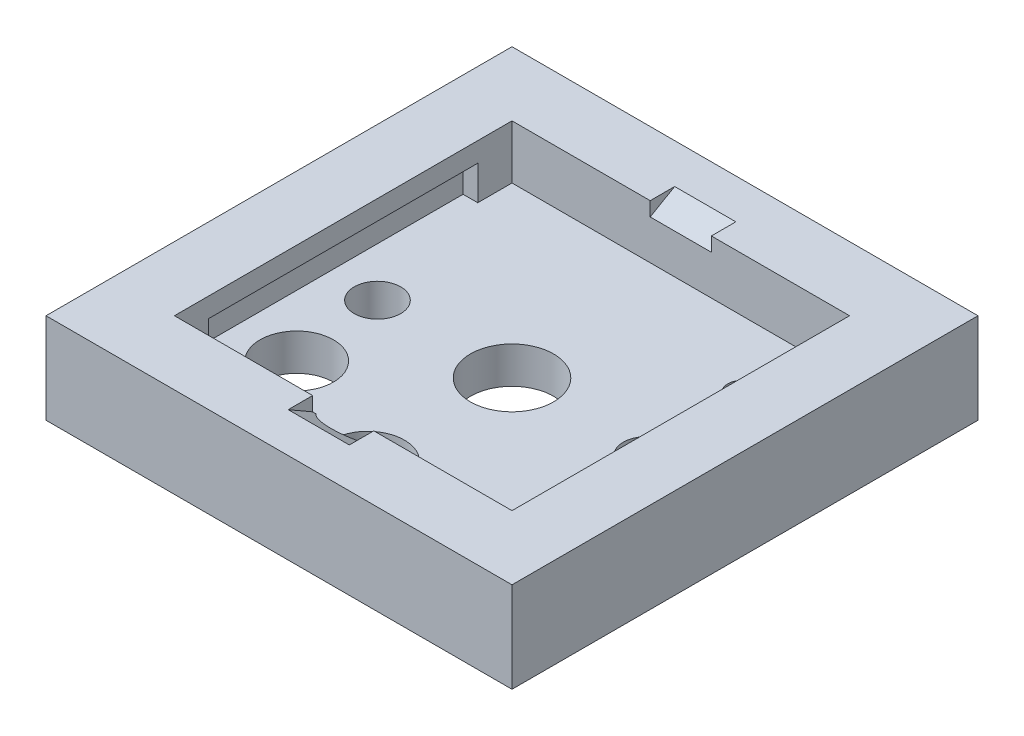
from build123d import *

# Parameters (mm, degrees)
SKETCH1_W           = 19.05
SKETCH1_H           = 19.05
SKETCH1_R           = 1.5
SKETCH1_R_2         = 0.95
SKETCH1_R_3         = 1.7
SKETCH1_R_4         = 0.6
BOSS_EXTRUDE1_DEPTH = 3.7
CUT_EXTRUDE1_START  = 3.7
SKETCH1_3_R         = 1.5
SKETCH1_3_R_2       = 0.95
SKETCH1_3_R_3       = 1.7
SKETCH1_3_R_4       = 0.6
CUT_EXTRUDE1_DEPTH  = 2.2
CUT_EXTRUDE2_DEPTH  = 1.25
CUT_EXTRUDE3_DEPTH  = 5.5


with BuildPart() as part:
    # Sketch1 → Boss-Extrude1 (new body)
    with BuildSketch(Plane(origin=(0, 0, 0), x_dir=(1, 0, 0), z_dir=(0, 1, 0))):
        Rectangle(SKETCH1_W, SKETCH1_H)
        with BuildLine():
            Line((-6.9, -6.9), (-6.9, 6.9))
            Line((-6.9, 6.9), (6.9, 6.9))
            Line((6.9, 6.9), (6.9, -6.9))
            Line((6.9, -6.9), (1.118033989, -6.9))
            ThreePointArc((1.118033989, -6.9), (0, -7.4), (-1.118033989, -6.9))
            Line((-1.118033989, -6.9), (-6.9, -6.9))
        make_face(mode=Mode.SUBTRACT)
        with BuildLine():
            Line((6.9, 6.9), (-6.9, 6.9))
            Line((-6.9, 6.9), (-6.9, -6.9))
            Line((-6.9, -6.9), (-1.118033989, -6.9))
            ThreePointArc((-1.118033989, -6.9), (-0.535233135, -4.498741462), (1.5, -5.9))
            ThreePointArc((1.5, -5.9), (1.401258538, -6.435233135), (1.118033989, -6.9))
            Line((1.118033989, -6.9), (6.9, -6.9))
            Line((6.9, -6.9), (6.9, 6.9))
        make_face()
        with Locations((-5, -3.8)):
            Circle(SKETCH1_R, mode=Mode.SUBTRACT)
        with Locations((5.5, 0)):
            Circle(SKETCH1_R_2, mode=Mode.SUBTRACT)
        with Locations((-5.5, 0)):
            Circle(SKETCH1_R_2, mode=Mode.SUBTRACT)
        Circle(SKETCH1_R_3, mode=Mode.SUBTRACT)
        with Locations((5.22, 4.2)):
            Circle(SKETCH1_R_4, mode=Mode.SUBTRACT)
    extrude(amount=BOSS_EXTRUDE1_DEPTH)

    # Sketch1_3 → Cut-Extrude1 (cut)
    with BuildSketch(Plane(origin=(0, 0, 0), x_dir=(1, 0, 0), z_dir=(0, 1, 0)).offset(CUT_EXTRUDE1_START)):
        with BuildLine():
            Line((6.9, 6.9), (-6.9, 6.9))
            Line((-6.9, 6.9), (-6.9, -6.9))
            Line((-6.9, -6.9), (-1.118033989, -6.9))
            ThreePointArc((-1.118033989, -6.9), (-0.535233135, -4.498741462), (1.5, -5.9))
            ThreePointArc((1.5, -5.9), (1.401258538, -6.435233135), (1.118033989, -6.9))
            Line((1.118033989, -6.9), (6.9, -6.9))
            Line((6.9, -6.9), (6.9, 6.9))
        make_face()
        with Locations((-5, -3.8)):
            Circle(SKETCH1_3_R, mode=Mode.SUBTRACT)
        with Locations((5.5, 0)):
            Circle(SKETCH1_3_R_2, mode=Mode.SUBTRACT)
        with Locations((-5.5, 0)):
            Circle(SKETCH1_3_R_2, mode=Mode.SUBTRACT)
        Circle(SKETCH1_3_R_3, mode=Mode.SUBTRACT)
        with Locations((5.22, 4.2)):
            Circle(SKETCH1_3_R_4, mode=Mode.SUBTRACT)
    extrude(amount=-CUT_EXTRUDE1_DEPTH, mode=Mode.SUBTRACT)

    # Sketch2 → Cut-Extrude2 (cut, symmetric)
    with BuildSketch(Plane(origin=(0, 0, 0), x_dir=(0, 0, -1), z_dir=(1, 0, 0))):
        Polygon((-7.9, 3.7), (-6.9, 3.7), (-6.9, 3.122649731), align=None)
    cut_extrude2 = extrude(amount=CUT_EXTRUDE2_DEPTH, both=True, mode=Mode.SUBTRACT)

    # Mirror1: Cut-Extrude2 across plane
    add(cut_extrude2.mirror(Plane.XY), mode=Mode.SUBTRACT)

    # Sketch4 → Cut-Extrude3 (cut, symmetric)
    with BuildSketch(Plane.XY):
        Polygon((-6.9, 2.9), (-6.9, 1.5), (-7.5, 1.5), (-7.5, 2.8), (-7, 2.8), align=None)
    cut_extrude3 = extrude(amount=CUT_EXTRUDE3_DEPTH, both=True, mode=Mode.SUBTRACT)

    # Mirror2: Cut-Extrude3 across plane
    add(cut_extrude3.mirror(Plane(origin=(0, 0, 0), x_dir=(0, 0, 1), z_dir=(1, 0, 0))), mode=Mode.SUBTRACT)


solid = part.part
